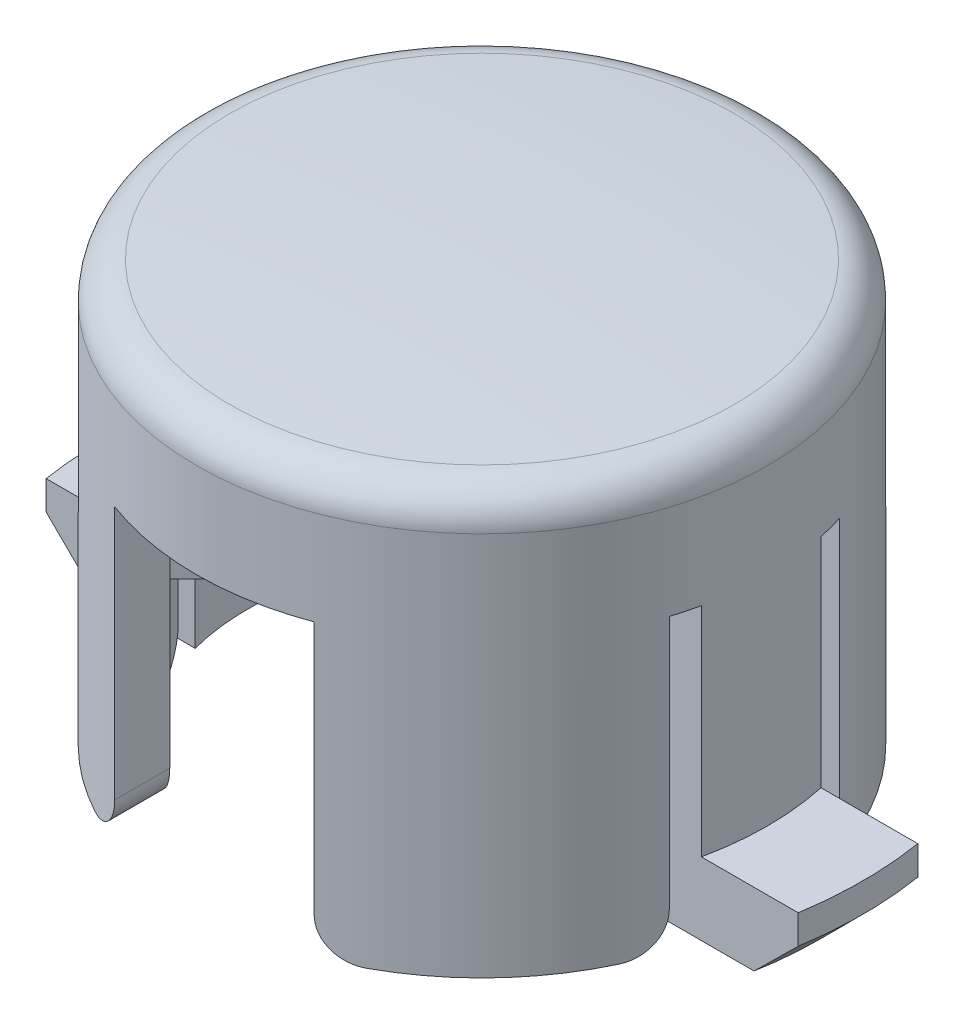
from build123d import *

# Parameters (mm, degrees)
SKETCH2_W     = 6.985
SKETCH2_H     = 32.356336156
SKETCH2_W_2   = 40.972237954
SKETCH2_H_2   = 0.889
CUTOUT_DEPTH  = 10.16
TAB_DEPTH     = 2.54
TAB_CHMF_SIZE = 1.524
CROSS_DEPTH   = 7.62
SKETCH4_W     = 3.302
SKETCH4_H     = 7.6962
BOX_DEPTH     = 13.059399
SKETCH6_W     = 1.778
SKETCH6_H     = 6.1722
BOXCUT_DEPTH  = 13.059399
FILLET1_R     = 1.27


with BuildPart() as part:
    # Sketch1 → dome/base (revolve)
    with BuildSketch(Plane.XY):
        with BuildLine():
            Line((0, 6.039891065), (0, 3.960890157))
            Line((0, 3.960890157), (8.222, 3.960890157))
            Line((8.222, 3.960890157), (8.222, -9.047708935))
            Line((8.222, -9.047708935), (10, -9.047708935))
            Line((10, -9.047708935), (10, 4.421422334))
            ThreePointArc((10, 4.421422334), (9.66312833, 5.282916106), (8.831225953, 5.687381775))
            ThreePointArc((8.831225953, 5.687381775), (4.419129287, 5.951728667), (0, 6.039891065))
        make_face()
    revolve(axis=Axis((0, 0, 0), (0, 1, 0)))

    # Sketch2 → cutout (cut)
    with BuildSketch(Plane.XZ.offset(9.047708935)):
        Rectangle(SKETCH2_W, SKETCH2_H)
        with Locations((0, 2.54)):
            Rectangle(SKETCH2_W_2, SKETCH2_H_2)
        with Locations((0, -2.54)):
            Rectangle(SKETCH2_W_2, SKETCH2_H_2)
    extrude(amount=-CUTOUT_DEPTH, mode=Mode.SUBTRACT)

    # Sketch3 → tab (add)
    with BuildSketch(Plane.XZ.offset(9.047708935)):
        with BuildLine():
            Line((-13.169324385, -2.0955), (-9.777979329, -2.0955))
            ThreePointArc((-9.777979329, -2.0955), (-10, 0), (-9.777979329, 2.0955))
            Line((-9.777979329, 2.0955), (-13.169324385, 2.0955))
            ThreePointArc((-13.169324385, 2.0955), (-13.335, 0), (-13.169324385, -2.0955))
        make_face()
        with BuildLine():
            Line((9.777979329, -2.0955), (13.169324385, -2.0955))
            ThreePointArc((13.169324385, -2.0955), (13.293516571, -1.051019583), (13.335, 0))
            ThreePointArc((13.335, 0), (13.293516571, 1.051019583), (13.169324385, 2.0955))
            Line((13.169324385, 2.0955), (9.777979329, 2.0955))
            ThreePointArc((9.777979329, 2.0955), (10, 0), (9.777979329, -2.0955))
        make_face()
    extrude(amount=-TAB_DEPTH)

    # tab chmf
    tab_chmf_edges = [part.edges().sort_by_distance(p)[0] for p in [
        (-13.335, -9.047708935, 0),
        (13.335, -9.047708935, 0),
    ]]
    chamfer(tab_chmf_edges, length=TAB_CHMF_SIZE)

    # Sketch5 → cross (add)
    with BuildSketch(Plane.XZ.offset(-3.960890157)):
        with BuildLine():
            Line((0, -0.71842049), (-0.71842049, 0))
            Line((-0.71842049, 0), (-6.161934605, -5.443514115))
            ThreePointArc((-6.161934605, -5.443514115), (-5.813831955, -5.813831955), (-5.443514115, -6.161934605))
            Line((-5.443514115, -6.161934605), (0, -0.71842049))
        make_face()
        with BuildLine():
            Line((6.161934605, -5.443514115), (0.71842049, 0))
            Line((0.71842049, 0), (0, -0.71842049))
            Line((0, -0.71842049), (5.443514115, -6.161934605))
            ThreePointArc((5.443514115, -6.161934605), (5.813831955, -5.813831955), (6.161934605, -5.443514115))
        make_face()
        with BuildLine():
            Line((5.443514115, 6.161934605), (0, 0.71842049))
            Line((0, 0.71842049), (0.71842049, 0))
            Line((0.71842049, 0), (6.161934605, 5.443514115))
            ThreePointArc((6.161934605, 5.443514115), (5.813831955, 5.813831955), (5.443514115, 6.161934605))
        make_face()
        Polygon((0.71842049, 0), (0, 0.71842049), (-0.71842049, 0), (0, -0.71842049), align=None)
        with BuildLine():
            Line((-0.71842049, 0), (0, 0.71842049))
            Line((0, 0.71842049), (-5.443514115, 6.161934605))
            ThreePointArc((-5.443514115, 6.161934605), (-5.813831955, 5.813831955), (-6.161934605, 5.443514115))
            Line((-6.161934605, 5.443514115), (-0.71842049, 0))
        make_face()
    extrude(amount=CROSS_DEPTH)

    # Sketch4 → box (add)
    with BuildSketch(Plane.XZ.offset(-3.960890157)):
        Rectangle(SKETCH4_W, SKETCH4_H)
    extrude(amount=BOX_DEPTH)

    # Sketch6 → boxcut (cut)
    with BuildSketch(Plane.XZ.offset(9.098508935)):
        Rectangle(SKETCH6_W, SKETCH6_H)
    extrude(amount=-BOXCUT_DEPTH, mode=Mode.SUBTRACT)

    # Fillet1
    fillet1_edges = [part.edges().sort_by_distance(p)[0] for p in [
        (-3.4925, -9.047708935, -8.406831929),
        (3.4925, -9.047708935, -8.406831929),
        (8.602728257, -9.047708935, -2.9845),
        (-8.602728257, -9.047708935, -2.9845),
        (-3.4925, -9.047708935, 8.406831929),
        (3.4925, -9.047708935, 8.406831929),
        (-8.602728257, -9.047708935, 2.9845),
        (8.602728257, -9.047708935, 2.9845),
    ]]
    fillet(fillet1_edges, radius=FILLET1_R)


solid = part.part
